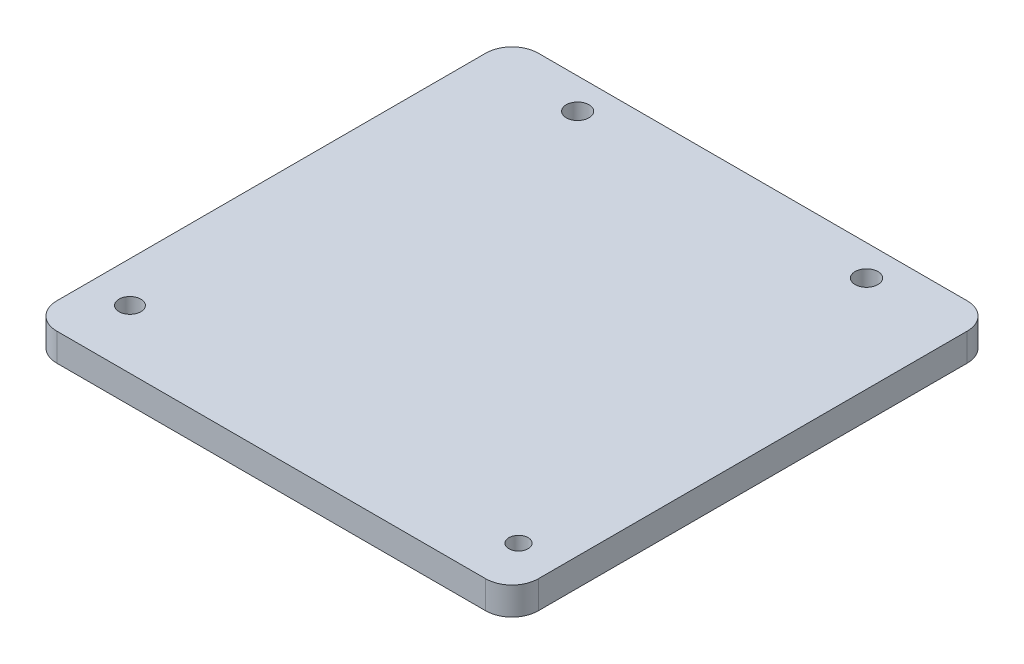
from build123d import *

# Parameters (mm, degrees)
SKETCH1_W           = 55
SKETCH1_H           = 55
BOSS_EXTRUDE1_DEPTH = 3.175
FILLET1_R           = 3
SKETCH3_R           = 1.1
SKETCH3_R_2         = 1.25
CUT_EXTRUDE2_DEPTH  = 3.175
SKETCH6_R           = 1.3
CUT_EXTRUDE5_DEPTH  = 3.175


with BuildPart() as part:
    # Sketch1 → Boss-Extrude1 (new body)
    with BuildSketch(Plane(origin=(0, 0, 0), x_dir=(1, 0, 0), z_dir=(0, 1, 0))):
        Rectangle(SKETCH1_W, SKETCH1_H)
    extrude(amount=BOSS_EXTRUDE1_DEPTH)

    # Fillet1
    fillet1_edges = [part.edges().sort_by_distance(p)[0] for p in [
        (27.5, 1.5875, 27.5),
        (-27.5, 1.5875, 27.5),
        (-27.5, 1.5875, -27.5),
        (27.5, 1.5875, -27.5),
    ]]
    fillet(fillet1_edges, radius=FILLET1_R)

    # Sketch3 → Cut-Extrude2 (cut)
    with BuildSketch(Plane(origin=(0, 3.175, 0), x_dir=(1, 0, 0), z_dir=(0, 1, 0))):
        with Locations((22.855, -22.11)):
            Circle(SKETCH3_R)
        with Locations((-22.865, -20.78)):
            Circle(SKETCH3_R_2)
    extrude(amount=-CUT_EXTRUDE2_DEPTH, mode=Mode.SUBTRACT)

    # Sketch6 → Cut-Extrude5 (cut)
    with BuildSketch(Plane(origin=(0, 3.175, 0), x_dir=(1, 0, 0), z_dir=(0, 1, 0))):
        with Locations((-16.5, 24)):
            Circle(SKETCH6_R)
        with Locations((16.5, 24)):
            Circle(SKETCH6_R)
    extrude(amount=-CUT_EXTRUDE5_DEPTH, mode=Mode.SUBTRACT)


solid = part.part
